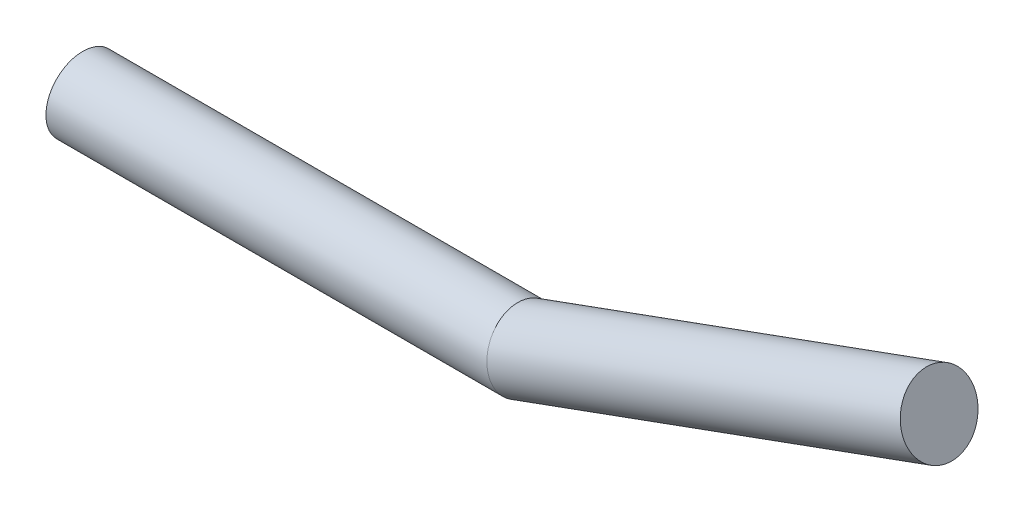
from build123d import *

# Parameters (mm, degrees)
SKETCH_2_R = 0.5


with BuildPart() as part:
    # 扫描1: sweep along a path in 草图1
    with BuildLine(Plane.XY) as sweep_1_path:
        Line((0, 0), (6, 0))
        Line((6, 0), (11.638155725, 2.05212086))
    # 草图2 → 扫描1 (sweep)
    with BuildSketch(Plane(origin=(0, 0, 0), x_dir=(0, 0, -1), z_dir=(1, 0, 0))):
        Circle(SKETCH_2_R)
    sweep(path=sweep_1_path.line, transition=Transition.RIGHT)


solid = part.part
